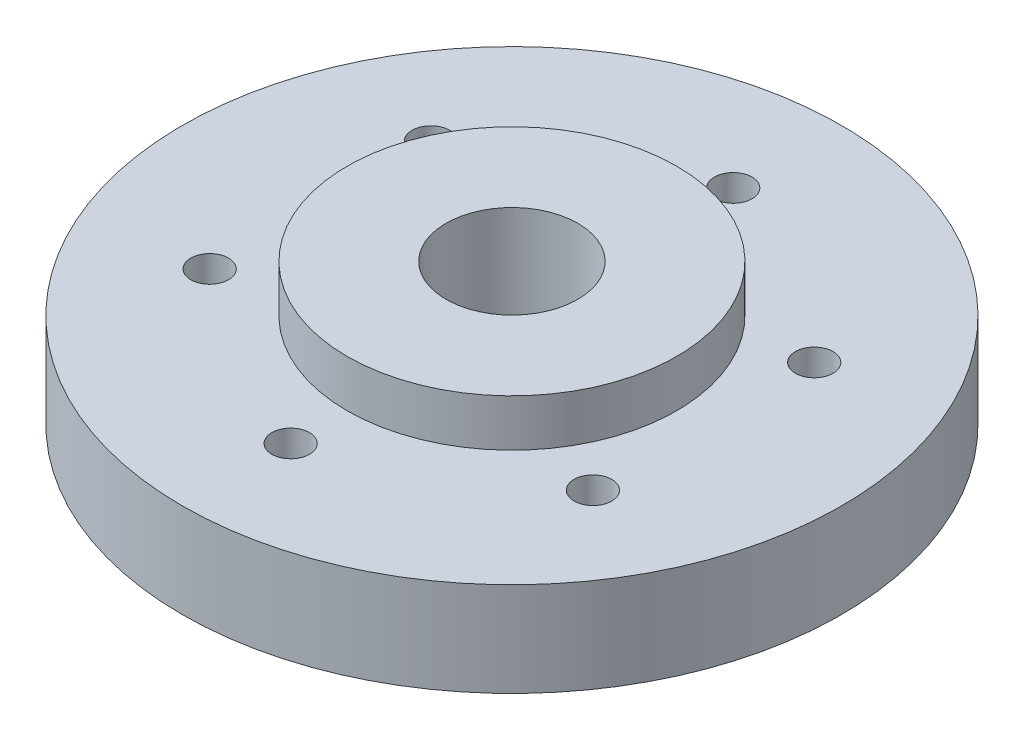
from build123d import *

# Parameters (mm, degrees)
SKETCH1_R           = 35
BOSS_EXTRUDE1_DEPTH = 15
SKETCH3_R           = 15.75
CUT_EXTRUDE1_DEPTH  = 5
SKETCH4_R           = 7
CUT_EXTRUDE2_DEPTH  = 11
SKETCH5_R           = 35
SKETCH5_R_2         = 17.5
CUT_EXTRUDE3_DEPTH  = 5
SKETCH6_R           = 2
CUT_EXTRUDE4_DEPTH  = 11
SKETCH7_R           = 5
SKETCH7_R_2         = 2
CUT_EXTRUDE5_DEPTH  = 5


with BuildPart() as part:
    # Sketch1 → Boss-Extrude1 (new body)
    with BuildSketch(Plane(origin=(0, 0, 0), x_dir=(1, 0, 0), z_dir=(0, 1, 0))):
        Circle(SKETCH1_R)
    extrude(amount=BOSS_EXTRUDE1_DEPTH)

    # Sketch3 → Cut-Extrude1 (cut)
    with BuildSketch(Plane.XZ):
        Circle(SKETCH3_R)
    extrude(amount=-CUT_EXTRUDE1_DEPTH, mode=Mode.SUBTRACT)

    # Sketch4 → Cut-Extrude2 (cut, through all)
    with BuildSketch(Plane.XZ.offset(-5)):
        Circle(SKETCH4_R)
    extrude(amount=-CUT_EXTRUDE2_DEPTH, mode=Mode.SUBTRACT)

    # Sketch5 → Cut-Extrude3 (cut)
    with BuildSketch(Plane(origin=(0, 15, 0), x_dir=(1, 0, 0), z_dir=(0, 1, 0))):
        Circle(SKETCH5_R)
        Circle(SKETCH5_R_2, mode=Mode.SUBTRACT)
    extrude(amount=-CUT_EXTRUDE3_DEPTH, mode=Mode.SUBTRACT)

    # Sketch6 → Cut-Extrude4 (cut, through all)
    with BuildSketch(Plane(origin=(0, 10, 0), x_dir=(1, 0, 0), z_dir=(0, 1, 0))):
        with Locations((0, 23.5)):
            Circle(SKETCH6_R)
        with Locations((20.351596989, 11.75)):
            Circle(SKETCH6_R)
        with Locations((20.351596989, -11.75)):
            Circle(SKETCH6_R)
        with Locations((0, -23.5)):
            Circle(SKETCH6_R)
        with Locations((-20.351596989, -11.75)):
            Circle(SKETCH6_R)
        with Locations((-20.351596989, 11.75)):
            Circle(SKETCH6_R)
    extrude(amount=-CUT_EXTRUDE4_DEPTH, mode=Mode.SUBTRACT)

    # Sketch7 → Cut-Extrude5 (cut)
    with BuildSketch(Plane.XZ):
        with Locations((0, 23.5)):
            Circle(SKETCH7_R)
        with Locations((0, 23.5)):
            Circle(SKETCH7_R_2, mode=Mode.SUBTRACT)
        with Locations((20.351596989, 11.75)):
            Circle(SKETCH7_R)
        with Locations((20.351596989, 11.75)):
            Circle(SKETCH7_R_2, mode=Mode.SUBTRACT)
        with Locations((20.351596989, -11.75)):
            Circle(SKETCH7_R)
        with Locations((20.351596989, -11.75)):
            Circle(SKETCH7_R_2, mode=Mode.SUBTRACT)
        with Locations((0, -23.5)):
            Circle(SKETCH7_R)
        with Locations((0, -23.5)):
            Circle(SKETCH7_R_2, mode=Mode.SUBTRACT)
        with Locations((-20.351596989, -11.75)):
            Circle(SKETCH7_R)
        with Locations((-20.351596989, -11.75)):
            Circle(SKETCH7_R_2, mode=Mode.SUBTRACT)
        with Locations((-20.351596989, 11.75)):
            Circle(SKETCH7_R)
        with Locations((-20.351596989, 11.75)):
            Circle(SKETCH7_R_2, mode=Mode.SUBTRACT)
    extrude(amount=-CUT_EXTRUDE5_DEPTH, mode=Mode.SUBTRACT)


solid = part.part
